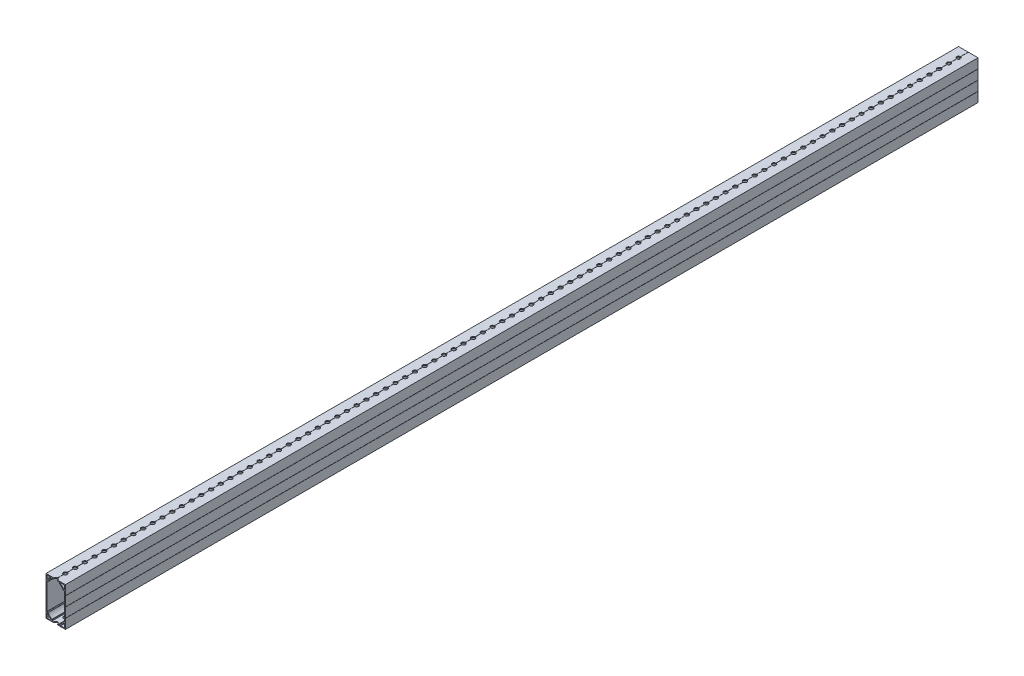
from build123d import *

# Parameters (mm, degrees)
BOSS_EXTRUDE1_DEPTH = 1193.8
SKETCH2_R           = 2.54
CUT_EXTRUDE1_DEPTH  = 51.8
LPATTERN1_COUNT     = 95
LPATTERN1_PITCH     = 12.7
FILLET1_R           = 0.254


with BuildPart() as part:
    # Sketch3 → Boss-Extrude1 (new body)
    with BuildSketch(Plane.XY):
        Polygon((12.7, -25.4), (0.127, -25.4), (0, -25.273), (-0.127, -25.4), (-12.7, -25.4), (-12.7, -12.827), (-12.573, -12.7), (-12.7, -12.573), (-12.7, -0.127), (-12.573, 0), (-12.7, 0.127), (-12.7, 12.573), (-12.573, 12.7), (-12.7, 12.827), (-12.7, 25.4), (-0.127, 25.4), (0, 25.273), (0.127, 25.4), (12.7, 25.4), (12.7, 12.827), (12.573, 12.7), (12.7, 12.573), (12.7, 0.127), (12.573, 0), (12.7, -0.127), (12.7, -12.573), (12.573, -12.7), (12.7, -12.827), align=None)
        with BuildLine():
            Line((-10.992410974, -24.384), (-6.597089026, -24.384))
            ThreePointArc((-6.597089026, -24.384), (-5.930604499, -23.877055919), (-6.241204261, -23.09941737))
            ThreePointArc((-6.241204261, -23.09941737), (-8.576144596, -21.276144596), (-10.39941737, -18.941204261))
            ThreePointArc((-10.39941737, -18.941204261), (-11.177055919, -18.630604499), (-11.684, -19.297089026))
            Line((-11.684, -19.297089026), (-11.684, -23.692410974))
            ThreePointArc((-11.684, -23.692410974), (-11.481438264, -24.181438264), (-10.992410974, -24.384))
        make_face(mode=Mode.SUBTRACT)
        with BuildLine():
            Line((11.684, 0), (11.684, -17.5895))
            Line((11.684, -17.5895), (9.979000251, -17.5895))
            ThreePointArc((9.979000251, -17.5895), (7.857724106, -20.557724106), (4.8895, -22.679000251))
            Line((4.8895, -22.679000251), (4.8895, -24.384))
            Line((4.8895, -24.384), (-4.8895, -24.384))
            Line((-4.8895, -24.384), (-4.8895, -22.679000251))
            ThreePointArc((-4.8895, -22.679000251), (-7.857724106, -20.557724106), (-9.979000251, -17.5895))
            Line((-9.979000251, -17.5895), (-11.684, -17.5895))
            Line((-11.684, -17.5895), (-11.684, 0))
            Line((-11.684, 0), (-11.684, 17.5895))
            Line((-11.684, 17.5895), (-9.979000251, 17.5895))
            ThreePointArc((-9.979000251, 17.5895), (-7.857724106, 20.557724106), (-4.8895, 22.679000251))
            Line((-4.8895, 22.679000251), (-4.8895, 24.384))
            Line((-4.8895, 24.384), (4.8895, 24.384))
            Line((4.8895, 24.384), (4.8895, 22.679000251))
            ThreePointArc((4.8895, 22.679000251), (7.857724106, 20.557724106), (9.979000251, 17.5895))
            Line((9.979000251, 17.5895), (11.684, 17.5895))
            Line((11.684, 17.5895), (11.684, 0))
        make_face(mode=Mode.SUBTRACT)
        with BuildLine():
            Line((11.684, -19.297089026), (11.684, -23.692410974))
            ThreePointArc((11.684, -23.692410974), (11.481438264, -24.181438264), (10.992410974, -24.384))
            Line((10.992410974, -24.384), (6.597089026, -24.384))
            ThreePointArc((6.597089026, -24.384), (5.930604499, -23.877055919), (6.241204261, -23.09941737))
            ThreePointArc((6.241204261, -23.09941737), (8.576144596, -21.276144596), (10.39941737, -18.941204261))
            ThreePointArc((10.39941737, -18.941204261), (11.177055919, -18.630604499), (11.684, -19.297089026))
        make_face(mode=Mode.SUBTRACT)
        with BuildLine():
            Line((10.992410974, 24.384), (6.597089026, 24.384))
            ThreePointArc((6.597089026, 24.384), (5.930604499, 23.877055919), (6.241204261, 23.09941737))
            ThreePointArc((6.241204261, 23.09941737), (8.576144596, 21.276144596), (10.39941737, 18.941204261))
            ThreePointArc((10.39941737, 18.941204261), (11.177055919, 18.630604499), (11.684, 19.297089026))
            Line((11.684, 19.297089026), (11.684, 23.692410974))
            ThreePointArc((11.684, 23.692410974), (11.481438264, 24.181438264), (10.992410974, 24.384))
        make_face(mode=Mode.SUBTRACT)
        with BuildLine():
            Line((-11.684, 19.297089026), (-11.684, 23.692410974))
            ThreePointArc((-11.684, 23.692410974), (-11.481438264, 24.181438264), (-10.992410974, 24.384))
            Line((-10.992410974, 24.384), (-6.597089026, 24.384))
            ThreePointArc((-6.597089026, 24.384), (-5.930604499, 23.877055919), (-6.241204261, 23.09941737))
            ThreePointArc((-6.241204261, 23.09941737), (-8.576144596, 21.276144596), (-10.39941737, 18.941204261))
            ThreePointArc((-10.39941737, 18.941204261), (-11.177055919, 18.630604499), (-11.684, 19.297089026))
        make_face(mode=Mode.SUBTRACT)
    extrude(amount=BOSS_EXTRUDE1_DEPTH)

    # Sketch2 → Cut-Extrude1 (cut, through all)
    with BuildSketch(Plane(origin=(25.4, 25.4, 0), x_dir=(0, 0, 1), z_dir=(0, -1, 0))):
        with Locations((12.7, 25.4)):
            Circle(SKETCH2_R)
    cut_extrude1 = extrude(amount=CUT_EXTRUDE1_DEPTH, mode=Mode.SUBTRACT)

    # LPattern1: Cut-Extrude1 ×95
    with Locations(*[(0, 0, i * LPATTERN1_PITCH) for i in range(1, LPATTERN1_COUNT)]):
        add(cut_extrude1, mode=Mode.SUBTRACT)

    # Fillet1
    fillet1_edges = [part.edges().sort_by_distance(p)[0] for p in [
        (-11.684, -17.5895, 596.9),
        (-9.979000251, -17.5895, 596.9),
        (-4.8895, -22.679000251, 596.9),
        (-4.8895, -24.384, 596.9),
        (4.8895, -24.384, 596.9),
        (4.8895, -22.679000251, 596.9),
        (9.979000251, -17.5895, 596.9),
        (11.684, -17.5895, 596.9),
        (11.684, 17.5895, 596.9),
        (9.979000251, 17.5895, 596.9),
        (4.8895, 22.679000251, 596.9),
        (4.8895, 24.384, 596.9),
        (-4.8895, 24.384, 596.9),
        (-4.8895, 22.679000251, 596.9),
        (-9.979000251, 17.5895, 596.9),
        (-11.684, 17.5895, 596.9),
    ]]
    fillet(fillet1_edges, radius=FILLET1_R)


solid = part.part
